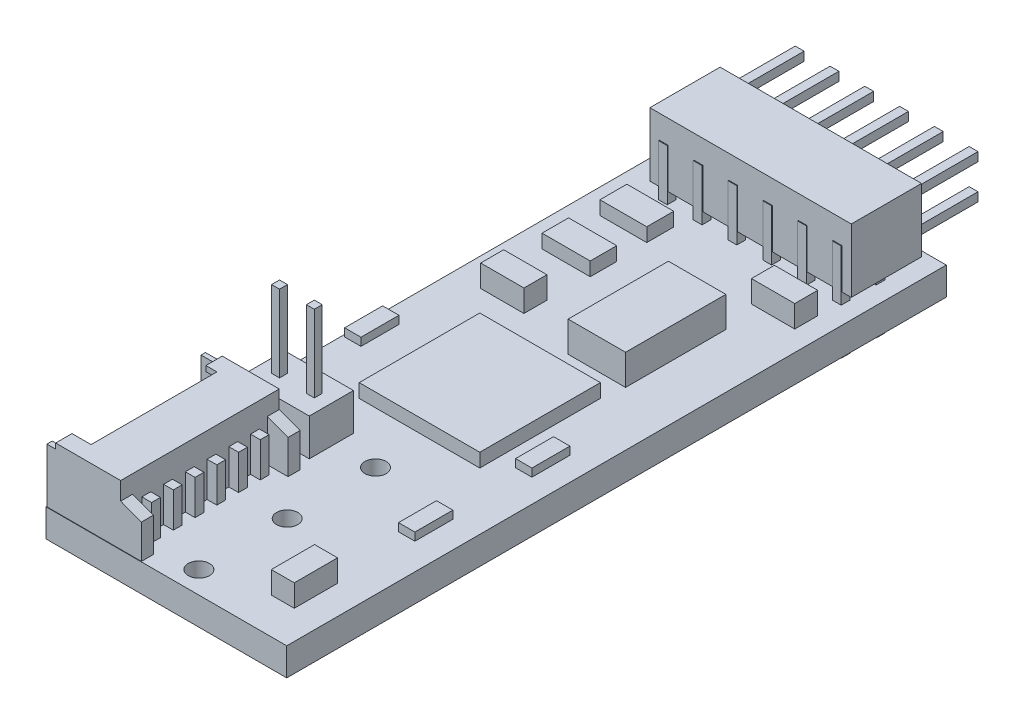
from build123d import *

# Parameters (mm, degrees)
SKETCH1_W                        = 13.843
SKETCH1_H                        = 37.9222
SKETCH1_R                        = 0.6096
PCB_OUTLINE_DEPTH                = 1.6002
INTERFACE_CONNECTOR_1_DEPTH      = 3.429
SKETCH3_W                        = 8.5598
SKETCH3_H                        = 2.8702
INTERFACE_CONNECTOR_2_DEPTH      = 2.794
INTERFACE_CONNECTOR_3_DEPTH      = 9.1186
INTERFACE_CONNECTOR_4_DEPTH      = 0.3048
SKETCH6_W                        = 11.5824
SKETCH6_H                        = 4.0386
MAIN_CONNECTOR_HOUSING_DEPTH     = 3.6576
SKETCH7_W                        = 0.508
SKETCH7_H                        = 0.508
MAIN_CONNECTOR_PINS_1_DEPTH      = 3.7846
MAIN_CONNECTOR_PINS_2_COUNT      = 6
MAIN_CONNECTOR_PINS_2_PITCH      = 2
MAIN_CONNECTOR_PINS_2_COUNT_DIR2 = 2
MAIN_CONNECTOR_PINS_2_PITCH_DIR2 = 2
SKETCH8_W                        = 0.508
SKETCH8_H                        = 0.508
MAIN_CONNECTOR_PINS_3_DEPTH      = 5.588
MAIN_CONNECTOR_PINS_4_COUNT      = 6
MAIN_CONNECTOR_PINS_4_PITCH      = 2
MAIN_CONNECTOR_PINS_4_COUNT_DIR2 = 2
MAIN_CONNECTOR_PINS_4_PITCH_DIR2 = 2
SKETCH9_W                        = 3.9624
SKETCH9_H                        = 2.54
LOCK_CONNECTOR_HOUSING_DEPTH     = 2.1336
SKETCH10_W                       = 0.4572
SKETCH10_H                       = 0.4572
LOCK_CONNECTOR_PINS_DEPTH        = 8.6614
SKETCH11_W                       = 0.762
SKETCH11_H                       = 0.508
INTERFACE_CONNECTOR_PINS_1_DEPTH = 4.1148
INTERFACE_CONNECTOR_PINS_2_COUNT = 6
INTERFACE_CONNECTOR_PINS_2_PITCH = 1.25
SKETCH12_W                       = 0.9398
SKETCH12_H                       = 2.1844
SKETCH12_W_2                     = 2.1844
SKETCH12_H_2                     = 0.9398
RESISTORS_DEPTH                  = 0.4572
SKETCH13_W                       = 6.9342
SKETCH13_H                       = 6.9342
SKETCH13_W_2                     = 2.6924
SKETCH13_H_2                     = 1.5494
SKETCH13_W_3                     = 2.7686
SKETCH13_H_3                     = 1.524
DIODE_MCU_V_REG_DEPTH            = 0.7874
SKETCH14_W                       = 2.4892
SKETCH14_H                       = 1.3208
SKETCH14_W_2                     = 1.3208
SKETCH14_H_2                     = 2.4892
CAPACITORS_DEPTH                 = 1.27
SKETCH15_W                       = 3.302
SKETCH15_H                       = 5.7658
TRANSISTOR_DEPTH                 = 1.7526


with BuildPart() as part:
    # Sketch1 → PCB outline (new body)
    with BuildSketch(Plane(origin=(0, 0, 0), x_dir=(1, 0, 0), z_dir=(0, 1, 0))):
        with Locations((6.9215, -18.9611)):
            Rectangle(SKETCH1_W, SKETCH1_H)
        with Locations(Location((7.5184, -36.6522, 0), (0, 0, 270))):  # turned: the seam where the file's is
            Circle(SKETCH1_R, mode=Mode.SUBTRACT)
        with Locations(Location((7.5184, -31.5722, 0), (0, 0, 270))):  # turned: the seam where the file's is
            Circle(SKETCH1_R, mode=Mode.SUBTRACT)
        with Locations(Location((7.5184, -26.4922, 0), (0, 0, 270))):  # turned: the seam where the file's is
            Circle(SKETCH1_R, mode=Mode.SUBTRACT)
    extrude(amount=-PCB_OUTLINE_DEPTH)

    # Sketch2 → Interface connector 1 (add)
    with BuildSketch(Plane(origin=(0, 0, 0), x_dir=(1, 0, 0), z_dir=(0, 1, 0))):
        Polygon((0.0254, -37.8968), (5.461, -37.8968), (5.461, -37.211), (4.2672, -37.211), (4.2672, -29.464), (5.461, -29.464), (5.461, -28.7782), (0.0254, -28.7782), align=None)
    extrude(amount=INTERFACE_CONNECTOR_1_DEPTH)

    # Sketch3 → Interface connector 2 (cut)
    with BuildSketch(Plane.ZY.offset(-0.0254)):
        with Locations((33.3121, 1.6891)):
            Rectangle(SKETCH3_W, SKETCH3_H)
    extrude(amount=-INTERFACE_CONNECTOR_2_DEPTH, mode=Mode.SUBTRACT)

    # Sketch4 → Interface connector 3 (cut)
    with BuildSketch(Plane.XY.offset(37.8968)):
        Polygon((4.2672, 3.429), (4.2672, 2.403191117), (5.746000066, 1.852722801), (5.746000066, 3.429), align=None)
    extrude(amount=-INTERFACE_CONNECTOR_3_DEPTH, mode=Mode.SUBTRACT)

    # Sketch5 → Interface connector 4 (cut)
    with BuildSketch(Plane(origin=(0, 3.429, 0), x_dir=(1, 0, 0), z_dir=(0, 1, 0))):
        Polygon((0.9906, -28.7782), (0.9906, -29.718), (1.6256, -29.718), (1.6256, -36.957), (0.52813502, -36.957), (0.52813502, -37.8968), (-0.713810378, -37.8968), (-0.713810378, -28.7782), align=None)
    extrude(amount=-INTERFACE_CONNECTOR_4_DEPTH, mode=Mode.SUBTRACT)



with BuildPart() as body_2:
    # Sketch6 → Main connector housing (new body)
    with BuildSketch(Plane(origin=(0, 4.2926, 0), x_dir=(-1, 0, 0), z_dir=(0, 1, 0))):
        with Locations((-7.5692, 2.9591)):
            Rectangle(SKETCH6_W, SKETCH6_H)
    extrude(amount=-MAIN_CONNECTOR_HOUSING_DEPTH)

    # Sketch7 → Main connector pins 1 (add)
    with BuildSketch(Plane(origin=(0, 0, 0.9398), x_dir=(-1, 0, 0), z_dir=(0, 0, -1))):
        with Locations((-12.5692, 3.4638)):
            Rectangle(SKETCH7_W, SKETCH7_H)
    main_connector_pins_1 = extrude(amount=MAIN_CONNECTOR_PINS_1_DEPTH)

    # Main connector pins 2: Main connector pins 1 6 × 2
    with Locations(*[(-i * MAIN_CONNECTOR_PINS_2_PITCH, -j * MAIN_CONNECTOR_PINS_2_PITCH_DIR2, 0) for i in range(MAIN_CONNECTOR_PINS_2_COUNT) for j in range(MAIN_CONNECTOR_PINS_2_COUNT_DIR2) if (i, j) != (0, 0)]):
        add(main_connector_pins_1)


with BuildPart() as part_1:
    add(part.part)

    add(body_2.part)  # Main connector pins 3 merges body 2
    # Sketch8 → Main connector pins 3 (add)
    with BuildSketch(Plane.XZ.offset(2.6416)):
        with Locations((2.5692, 2.7686)):
            Rectangle(SKETCH8_W, SKETCH8_H)
    main_connector_pins_3 = extrude(amount=-MAIN_CONNECTOR_PINS_3_DEPTH)

    # Main connector pins 4: Main connector pins 3 6 × 2
    with Locations(*[(i * MAIN_CONNECTOR_PINS_4_PITCH, 0, j * MAIN_CONNECTOR_PINS_4_PITCH_DIR2) for i in range(MAIN_CONNECTOR_PINS_4_COUNT) for j in range(MAIN_CONNECTOR_PINS_4_COUNT_DIR2) if (i, j) != (0, 0)]):
        add(main_connector_pins_3)

    # Sketch9 → Lock connector housing (add)
    with BuildSketch(Plane(origin=(0, 0, 0), x_dir=(1, 0, 0), z_dir=(0, 1, 0))):
        with Locations((3.2004, -26.6954)):
            Rectangle(SKETCH9_W, SKETCH9_H)
    extrude(amount=LOCK_CONNECTOR_HOUSING_DEPTH)

    # Sketch10 → Lock connector pins (add)
    with BuildSketch(Plane(origin=(0, -2.1082, 0), x_dir=(1, 0, 0), z_dir=(0, 1, 0))):
        with Locations((4.2004, -26.6954)):
            Rectangle(SKETCH10_W, SKETCH10_H)
        with Locations((2.2004, -26.6954)):
            Rectangle(SKETCH10_W, SKETCH10_H)
    extrude(amount=LOCK_CONNECTOR_PINS_DEPTH)

    # Sketch11 → Interface connector pins 1 (add)
    with BuildSketch(Plane(origin=(0, -2.1082, 0), x_dir=(-1, 0, 0), z_dir=(0, 1, 0))):
        with Locations((-4.445, 36.4236)):
            Rectangle(SKETCH11_W, SKETCH11_H)
    interface_connector_pins_1 = extrude(amount=INTERFACE_CONNECTOR_PINS_1_DEPTH)

    # Interface connector pins 2: Interface connector pins 1 ×6
    with Locations(*[(0, 0, -i * INTERFACE_CONNECTOR_PINS_2_PITCH) for i in range(1, INTERFACE_CONNECTOR_PINS_2_COUNT)]):
        add(interface_connector_pins_1)

    # Sketch12 → Resistors (add)
    with BuildSketch(Plane(origin=(0, 0, 0), x_dir=(1, 0, 0), z_dir=(0, 1, 0))):
        with Locations((12.0269, -21.3868)):
            Rectangle(SKETCH12_W, SKETCH12_H)
        with Locations((11.8491, -27.94)):
            Rectangle(SKETCH12_W, SKETCH12_H)
        with Locations((0.5969, -19.7866)):
            Rectangle(SKETCH12_W, SKETCH12_H)
        with Locations((9.1186, -0.8509)):
            Rectangle(SKETCH12_W_2, SKETCH12_H_2)
        with Locations((5.2832, -0.8509)):
            Rectangle(SKETCH12_W_2, SKETCH12_H_2)
    extrude(amount=RESISTORS_DEPTH)

    # Sketch13 → Diode_ MCU_ V-reg (add)
    with BuildSketch(Plane(origin=(0, 0, 0), x_dir=(1, 0, 0), z_dir=(0, 1, 0))):
        with Locations((7.0739, -20.0533)):
            Rectangle(SKETCH13_W, SKETCH13_H)
        with Locations((2.7686, -6.7183)):
            Rectangle(SKETCH13_W_2, SKETCH13_H_2)
        with Locations((2.806616017, -10.0584)):
            Rectangle(SKETCH13_W_3, SKETCH13_H_3)
    extrude(amount=DIODE_MCU_V_REG_DEPTH)

    # Sketch14 → Capacitors (add)
    with BuildSketch(Plane(origin=(0, 0, 0), x_dir=(1, 0, 0), z_dir=(0, 1, 0))):
        with Locations((2.8702, -13.8938)):
            Rectangle(SKETCH14_W, SKETCH14_H)
        with Locations((11.5316, -34.5948)):
            Rectangle(SKETCH14_W_2, SKETCH14_H_2)
        with Locations((11.43, -6.8834)):
            Rectangle(SKETCH14_W, SKETCH14_H)
    extrude(amount=CAPACITORS_DEPTH)

    # Sketch15 → Transistor (add)
    with BuildSketch(Plane(origin=(0, 0, 0), x_dir=(1, 0, 0), z_dir=(0, 1, 0))):
        with Locations((9.0678, -12.4333)):
            Rectangle(SKETCH15_W, SKETCH15_H)
    extrude(amount=TRANSISTOR_DEPTH)


solid = part_1.part
